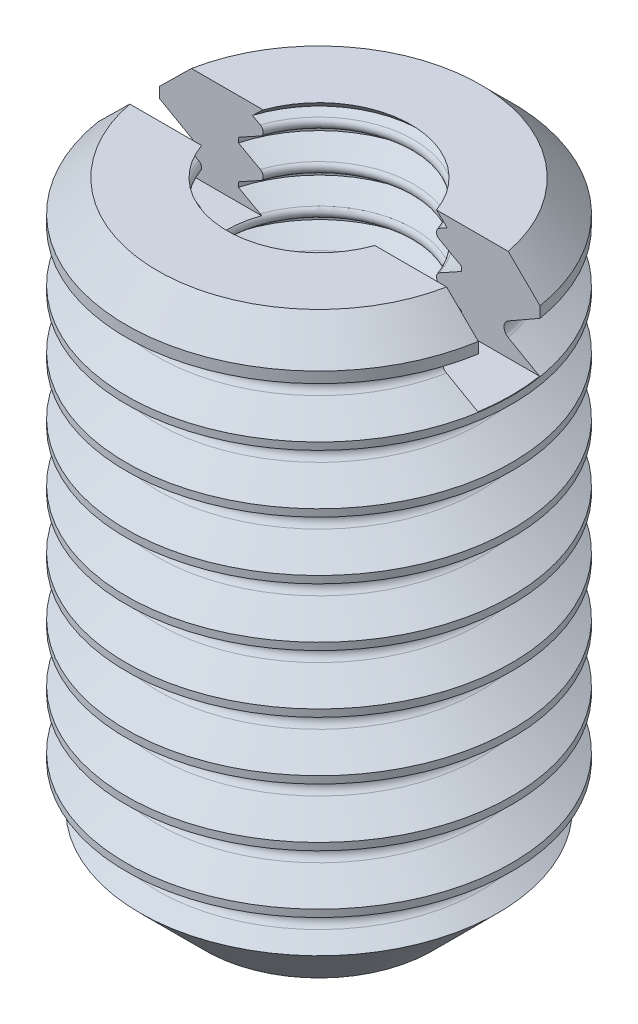
from build123d import *

# Parameters (mm, degrees)
SKETCH_2_W          = 13
SKETCH_2_H          = 1.6
CUT_EXTRUDE_1_DEPTH = 2.4


with BuildPart() as part:
    # 草图1 → 旋转2 (revolve)
    with BuildSketch(Plane.XY, mode=Mode.PRIVATE) as revolve_2_sk:
        with BuildLine():
            Line((157.408345239, 101.055722157), (158.220244055, 100.586972157))
            Line((158.220244055, 100.586972157), (158.220244055, 100.399472157))
            Line((158.220244055, 100.399472157), (157.408345239, 99.930722157))
            ThreePointArc((157.408345239, 99.930722157), (157.300092063, 99.743222157), (157.408345239, 99.555722157))
            Line((157.408345239, 99.555722157), (158.220244055, 99.086972157))
            Line((158.220244055, 99.086972157), (158.220244055, 98.899472157))
            Line((158.220244055, 98.899472157), (157.408345239, 98.430722157))
            ThreePointArc((157.408345239, 98.430722157), (157.300092063, 98.243222157), (157.408345239, 98.055722157))
            Line((157.408345239, 98.055722157), (158.220244055, 97.586972157))
            Line((158.220244055, 97.586972157), (158.220244055, 97.399472157))
            Line((158.220244055, 97.399472157), (157.408345239, 96.930722157))
            ThreePointArc((157.408345239, 96.930722157), (157.300092063, 96.743222157), (157.408345239, 96.555722157))
            Line((157.408345239, 96.555722157), (158.220244055, 96.086972157))
            Line((158.220244055, 96.086972157), (158.220244055, 95.899472157))
            Line((158.220244055, 95.899472157), (157.408345239, 95.430722157))
            ThreePointArc((157.408345239, 95.430722157), (157.300092063, 95.243222157), (157.408345239, 95.055722157))
            Line((157.408345239, 95.055722157), (158.220244055, 94.586972157))
            Line((158.220244055, 94.586972157), (158.220244055, 94.399472157))
            Line((158.220244055, 94.399472157), (157.408345239, 93.930722157))
            ThreePointArc((157.408345239, 93.930722157), (157.300092063, 93.743222157), (157.408345239, 93.555722157))
            Line((157.408345239, 93.555722157), (158.220244055, 93.086972157))
            Line((158.220244055, 93.086972157), (158.220244055, 92.899472157))
            Line((158.220244055, 92.899472157), (157.408345239, 92.430722157))
            ThreePointArc((157.408345239, 92.430722157), (157.300092063, 92.243222157), (157.408345239, 92.055722157))
            Line((157.408345239, 92.055722157), (158.220244055, 91.586972157))
            Line((158.220244055, 91.586972157), (158.220244055, 91.399472157))
            Line((158.220244055, 91.399472157), (157.408345239, 90.930722157))
            ThreePointArc((157.408345239, 90.930722157), (157.300092063, 90.743222157), (157.408345239, 90.555722157))
            Line((157.408345239, 90.555722157), (158.220244055, 90.086972157))
            Line((158.220244055, 90.086972157), (158.220244055, 89.899472157))
            Line((158.220244055, 89.899472157), (157.408345239, 89.430722157))
            ThreePointArc((157.408345239, 89.430722157), (157.300092063, 89.243222157), (157.408345239, 89.055722157))
            Line((157.408345239, 89.055722157), (157.867595686, 88.790573788))
            Line((157.867595686, 88.790573788), (156.164771278, 87.08774938))
            Line((156.164771278, 87.08774938), (155.678978177, 87.368222157))
            ThreePointArc((155.678978177, 87.368222157), (155.606809394, 87.493222157), (155.678978177, 87.618222157))
            Line((155.678978177, 87.618222157), (156.220244055, 87.930722157))
            Line((156.220244055, 87.930722157), (156.220244055, 88.055722157))
            Line((156.220244055, 88.055722157), (155.678978177, 88.368222157))
            ThreePointArc((155.678978177, 88.368222157), (155.606809394, 88.493222157), (155.678978177, 88.618222157))
            Line((155.678978177, 88.618222157), (156.220244055, 88.930722157))
            Line((156.220244055, 88.930722157), (156.220244055, 89.055722157))
            Line((156.220244055, 89.055722157), (155.678978177, 89.368222157))
            ThreePointArc((155.678978177, 89.368222157), (155.606809394, 89.493222157), (155.678978177, 89.618222157))
            Line((155.678978177, 89.618222157), (156.220244055, 89.930722157))
            Line((156.220244055, 89.930722157), (156.220244055, 90.055722157))
            Line((156.220244055, 90.055722157), (155.678978177, 90.368222157))
            ThreePointArc((155.678978177, 90.368222157), (155.606809394, 90.493222157), (155.678978177, 90.618222157))
            Line((155.678978177, 90.618222157), (156.220244055, 90.930722157))
            Line((156.220244055, 90.930722157), (156.220244055, 91.055722157))
            Line((156.220244055, 91.055722157), (155.678978177, 91.368222157))
            ThreePointArc((155.678978177, 91.368222157), (155.606809394, 91.493222157), (155.678978177, 91.618222157))
            Line((155.678978177, 91.618222157), (156.220244055, 91.930722157))
            Line((156.220244055, 91.930722157), (156.220244055, 92.055722157))
            Line((156.220244055, 92.055722157), (155.678978177, 92.368222157))
            ThreePointArc((155.678978177, 92.368222157), (155.606809394, 92.493222157), (155.678978177, 92.618222157))
            Line((155.678978177, 92.618222157), (156.220244055, 92.930722157))
            Line((156.220244055, 92.930722157), (156.220244055, 93.055722157))
            Line((156.220244055, 93.055722157), (155.678978177, 93.368222157))
            ThreePointArc((155.678978177, 93.368222157), (155.606809394, 93.493222157), (155.678978177, 93.618222157))
            Line((155.678978177, 93.618222157), (156.220244055, 93.930722157))
            Line((156.220244055, 93.930722157), (156.220244055, 94.055722157))
            Line((156.220244055, 94.055722157), (155.678978177, 94.368222157))
            ThreePointArc((155.678978177, 94.368222157), (155.606809394, 94.493222157), (155.678978177, 94.618222157))
            Line((155.678978177, 94.618222157), (156.220244055, 94.930722157))
            Line((156.220244055, 94.930722157), (156.220244055, 95.055722157))
            Line((156.220244055, 95.055722157), (155.678978177, 95.368222157))
            ThreePointArc((155.678978177, 95.368222157), (155.606809394, 95.493222157), (155.678978177, 95.618222157))
            Line((155.678978177, 95.618222157), (156.220244055, 95.930722157))
            Line((156.220244055, 95.930722157), (156.220244055, 96.055722157))
            Line((156.220244055, 96.055722157), (155.678978177, 96.368222157))
            ThreePointArc((155.678978177, 96.368222157), (155.606809394, 96.493222157), (155.678978177, 96.618222157))
            Line((155.678978177, 96.618222157), (156.220244055, 96.930722157))
            Line((156.220244055, 96.930722157), (156.220244055, 97.055722157))
            Line((156.220244055, 97.055722157), (155.678978177, 97.368222157))
            ThreePointArc((155.678978177, 97.368222157), (155.606809394, 97.493222157), (155.678978177, 97.618222157))
            Line((155.678978177, 97.618222157), (156.220244055, 97.930722157))
            Line((156.220244055, 97.930722157), (156.220244055, 98.055722157))
            Line((156.220244055, 98.055722157), (155.678978177, 98.368222157))
            ThreePointArc((155.678978177, 98.368222157), (155.606809394, 98.493222157), (155.678978177, 98.618222157))
            Line((155.678978177, 98.618222157), (156.220244055, 98.930722157))
            Line((156.220244055, 98.930722157), (156.220244055, 99.055722157))
            Line((156.220244055, 99.055722157), (155.678978177, 99.368222157))
            ThreePointArc((155.678978177, 99.368222157), (155.606809394, 99.493222157), (155.678978177, 99.618222157))
            Line((155.678978177, 99.618222157), (156.220244055, 99.930722157))
            Line((156.220244055, 99.930722157), (156.220244055, 100.055722157))
            Line((156.220244055, 100.055722157), (155.678978177, 100.368222157))
            ThreePointArc((155.678978177, 100.368222157), (155.606809394, 100.493222157), (155.678978177, 100.618222157))
            Line((155.678978177, 100.618222157), (156.220244055, 100.930722157))
            Line((156.220244055, 100.930722157), (156.220244055, 101.055722157))
            Line((156.220244055, 101.055722157), (155.678978177, 101.368222157))
            ThreePointArc((155.678978177, 101.368222157), (155.606809394, 101.493222157), (155.678978177, 101.618222157))
            Line((155.678978177, 101.618222157), (156.220244055, 101.930722157))
            Line((156.220244055, 101.930722157), (156.220244055, 102.055722157))
            Line((156.220244055, 102.055722157), (155.678978177, 102.368222157))
            ThreePointArc((155.678978177, 102.368222157), (155.606809394, 102.493222157), (155.678978177, 102.618222157))
            Line((155.678978177, 102.618222157), (155.870955751, 102.729060461))
            Line((155.870955751, 102.729060461), (155.606794055, 102.993222157))
            Line((155.606794055, 102.993222157), (157.408244055, 102.993222157))
            Line((157.408244055, 102.993222157), (158.220244055, 102.181222157))
            Line((158.220244055, 102.181222157), (158.220244055, 101.899472157))
            Line((158.220244055, 101.899472157), (157.408345239, 101.430722157))
            ThreePointArc((157.408345239, 101.430722157), (157.300092063, 101.243222157), (157.408345239, 101.055722157))
        make_face()
    revolve(revolve_2_sk.sketch.rotate(Axis((153.220244055, 87.08774938, 0), (0, 1, 0)), 90), axis=Axis((153.220244055, 87.08774938, 0), (0, 1, 0)))  # turned: the seam where the file's is

    # 草图2 → 切除-拉伸1 (cut)
    with BuildSketch(Plane(origin=(0, 102.993222157, 0), x_dir=(1, 0, 0), z_dir=(0, 1, 0))):
        with Locations((153.220244055, 0)):
            Rectangle(SKETCH_2_W, SKETCH_2_H)
    extrude(amount=-CUT_EXTRUDE_1_DEPTH, mode=Mode.SUBTRACT)


solid = part.part
